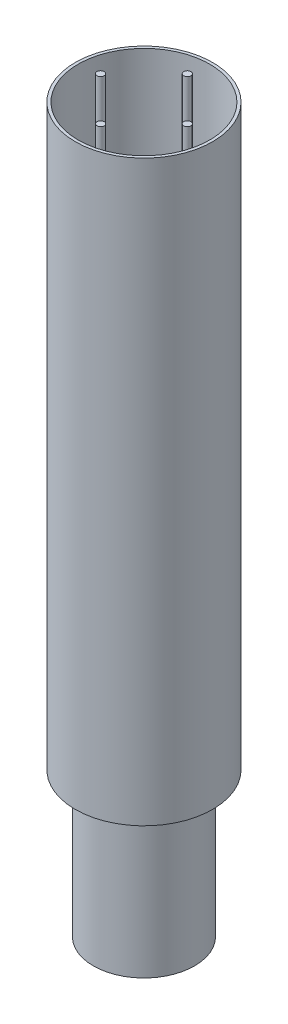
from build123d import *

# Parameters (mm, degrees)
SKETCH1_R             = 35
BOSS_EXTRUDE1_DEPTH   = 100
SKETCH2_R             = 47.5
BOSS_EXTRUDE2_DEPTH   = 400
SHELL1_T              = -2
SKETCH3_R             = 2.5
BOSS_EXTRUDE3_DEPTH   = 400
BOSS_EXTRUDE3_2_DEPTH = 400
BOSS_EXTRUDE3_3_DEPTH = 400
BOSS_EXTRUDE3_4_DEPTH = 400


with BuildPart() as part:
    # Sketch1 → Boss-Extrude1 (new body)
    with BuildSketch(Plane(origin=(0, 0, 0), x_dir=(1, 0, 0), z_dir=(0, 1, 0))):
        with Locations(Location((0, 0, 0), (0, 0, 270))):
            Circle(SKETCH1_R)
    extrude(amount=BOSS_EXTRUDE1_DEPTH)

    # Sketch2 → Boss-Extrude2 (add)
    with BuildSketch(Plane(origin=(0, 100, 0), x_dir=(1, 0, 0), z_dir=(0, 1, 0))):
        with Locations(Location((0, 0, 0), (0, 0, 270))):
            Circle(SKETCH2_R)
    extrude(amount=BOSS_EXTRUDE2_DEPTH)

    # Shell1
    shell1_openings = [part.faces().sort_by_distance(p)[0] for p in [
        (0, 500, 0),
    ]]
    offset(amount=SHELL1_T, openings=shell1_openings, kind=Kind.INTERSECTION)


with BuildPart() as body_2:
    # Sketch3 → Boss-Extrude3 (new body)
    with BuildSketch(Plane(origin=(0, 102, 0), x_dir=(1, 0, 0), z_dir=(0, 1, 0))):
        with Locations(Location((-30, 0, 0), (0, 0, 270))):
            Circle(SKETCH3_R)
    extrude(amount=BOSS_EXTRUDE3_DEPTH)


with BuildPart() as body_3:
    # Sketch3 → Boss-Extrude3 2 (new body)
    with BuildSketch(Plane(origin=(0, 102, 0), x_dir=(1, 0, 0), z_dir=(0, 1, 0))):
        with Locations(Location((0, 30, 0), (0, 0, 270))):
            Circle(SKETCH3_R)
    extrude(amount=BOSS_EXTRUDE3_2_DEPTH)


with BuildPart() as body_4:
    # Sketch3 → Boss-Extrude3 3 (new body)
    with BuildSketch(Plane(origin=(0, 102, 0), x_dir=(1, 0, 0), z_dir=(0, 1, 0))):
        with Locations(Location((30, 0, 0), (0, 0, 270))):
            Circle(SKETCH3_R)
    extrude(amount=BOSS_EXTRUDE3_3_DEPTH)


with BuildPart() as body_5:
    # Sketch3 → Boss-Extrude3 4 (new body)
    with BuildSketch(Plane(origin=(0, 102, 0), x_dir=(1, 0, 0), z_dir=(0, 1, 0))):
        with Locations(Location((0, -30, 0), (0, 0, 270))):
            Circle(SKETCH3_R)
    extrude(amount=BOSS_EXTRUDE3_4_DEPTH)


solid = Compound([part.part, body_2.part, body_3.part, body_4.part, body_5.part])
